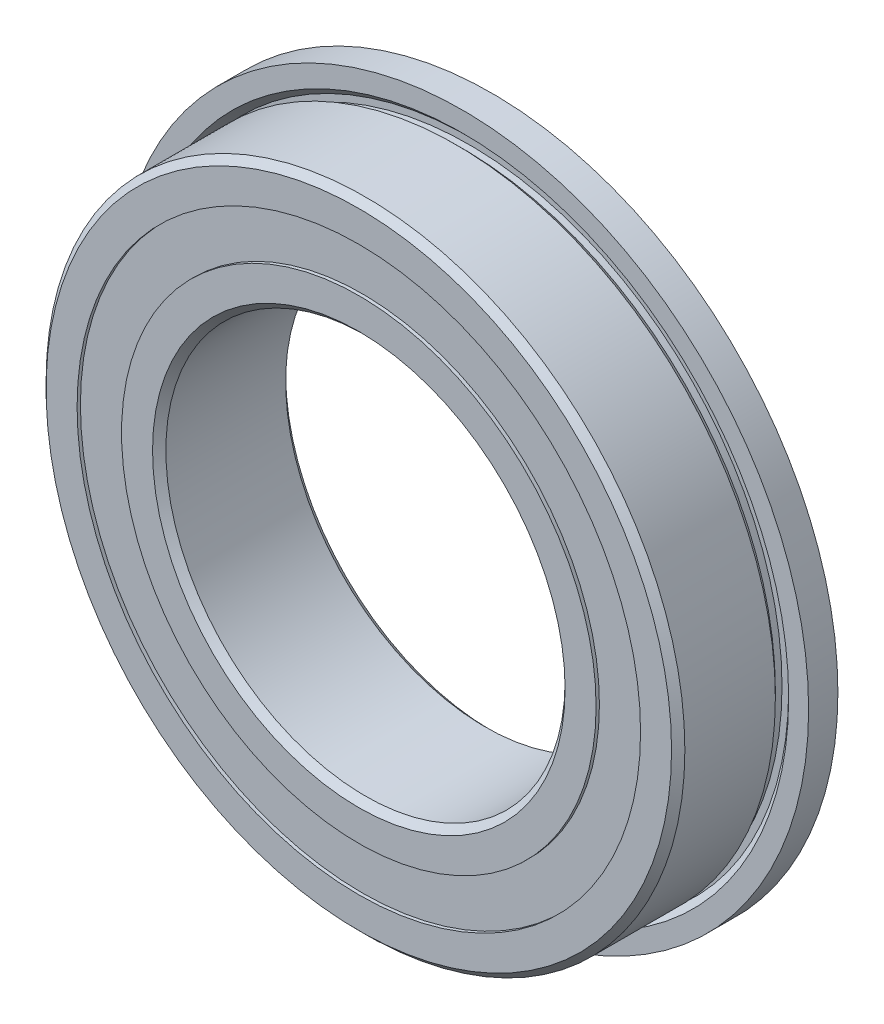
from build123d import *

# Parameters (mm, degrees)
SKETCH6_W         = 0.278388278
SKETCH6_H         = 0.835164836
CIRPATTERN1_COUNT = 14
SKETCH5_W         = 0.985011438
SKETCH5_H         = 1.67032967


with BuildPart() as part:
    # Sketch1 → Revolve1 (revolve)
    with BuildSketch(Plane(origin=(0, 0, 0), x_dir=(0, 0, -1), z_dir=(1, 0, 0))):
        with BuildLine():
            Line((-2.25, 12), (-2.5, 11.75))
            Line((-2.5, 11.75), (-2.5, 10.585164835))
            Line((-2.5, 10.585164835), (-1.111111111, 10.585164835))
            ThreePointArc((-1.111111111, 10.585164835), (0, 11.139988562), (1.111111111, 10.585164835))
            Line((1.111111111, 10.585164835), (2.5, 10.585164835))
            Line((2.5, 10.585164835), (2.5, 11.75))
            Line((2.5, 11.75), (2.5, 13))
            Line((2.5, 13), (1.4, 13))
            Line((1.4, 13), (1.4, 12.25))
            Line((1.4, 12.25), (1.65, 12))
            Line((1.65, 12), (1.65, 11.75))
            Line((1.65, 11.75), (1.4, 11.75))
            Line((1.4, 11.75), (1.15, 12))
            Line((1.15, 12), (-2.25, 12))
        make_face()
    revolve(axis=Axis((0, 0, 2.5), (0, 0, -1)))


with BuildPart() as body_2:
    # Sketch3 → Revolve3 (revolve)
    with BuildSketch(Plane(origin=(0, 0, 0), x_dir=(0, 0, -1), z_dir=(1, 0, 0))):
        with BuildLine():
            Line((-2.5, 8.914835165), (-1.111111111, 8.914835165))
            ThreePointArc((-1.111111111, 8.914835165), (0, 8.360011438), (1.111111111, 8.914835165))
            Line((1.111111111, 8.914835165), (2.5, 8.914835165))
            Line((2.5, 8.914835165), (2.5, 7.75))
            Line((2.5, 7.75), (2.25, 7.5))
            Line((2.25, 7.5), (-2.25, 7.5))
            Line((-2.25, 7.5), (-2.5, 7.75))
            Line((-2.5, 7.75), (-2.5, 8.914835165))
        make_face()
    revolve(axis=Axis((0, 0, 2.5), (0, 0, -1)))


with BuildPart() as body_3:
    # Sketch6 → Revolve6 (revolve)
    with BuildSketch(Plane(origin=(0, 0, 0), x_dir=(0, 0, -1), z_dir=(1, 0, 0))):
        with Locations((0, 9.75)):
            Rectangle(SKETCH6_W, SKETCH6_H)
    revolve(axis=Axis((0, 0, 2.5), (0, 0, -1)))


with BuildPart() as body_4:
    # Sketch4 → Revolve4 (revolve)
    with BuildSketch(Plane(origin=(0, 0, 0), x_dir=(0, 0, -1), z_dir=(1, 0, 0))):
        with BuildLine():
            Line((-1.389988562, 9.75), (1.389988562, 9.75))
            ThreePointArc((1.389988562, 9.75), (0, 11.139988562), (-1.389988562, 9.75))
        make_face()
    revolve(axis=Axis((0, 9.75, 1.389988562), (0, 0, -1)))


with BuildPart() as cirpattern1_1:
    # CirPattern1: pattern copy
    add(body_4.part.rotate(Axis((0, 0, -2.5), (0, 0, 1)), 1 * 360 / CIRPATTERN1_COUNT))


with BuildPart() as cirpattern1_2:
    # CirPattern1: pattern copy
    add(body_4.part.rotate(Axis((0, 0, -2.5), (0, 0, 1)), 2 * 360 / CIRPATTERN1_COUNT))


with BuildPart() as cirpattern1_3:
    # CirPattern1: pattern copy
    add(body_4.part.rotate(Axis((0, 0, -2.5), (0, 0, 1)), 3 * 360 / CIRPATTERN1_COUNT))


with BuildPart() as cirpattern1_4:
    # CirPattern1: pattern copy
    add(body_4.part.rotate(Axis((0, 0, -2.5), (0, 0, 1)), 4 * 360 / CIRPATTERN1_COUNT))


with BuildPart() as cirpattern1_5:
    # CirPattern1: pattern copy
    add(body_4.part.rotate(Axis((0, 0, -2.5), (0, 0, 1)), 5 * 360 / CIRPATTERN1_COUNT))


with BuildPart() as cirpattern1_6:
    # CirPattern1: pattern copy
    add(body_4.part.rotate(Axis((0, 0, -2.5), (0, 0, 1)), 6 * 360 / CIRPATTERN1_COUNT))


with BuildPart() as cirpattern1_7:
    # CirPattern1: pattern copy
    add(body_4.part.rotate(Axis((0, 0, -2.5), (0, 0, 1)), 7 * 360 / CIRPATTERN1_COUNT))


with BuildPart() as cirpattern1_8:
    # CirPattern1: pattern copy
    add(body_4.part.rotate(Axis((0, 0, -2.5), (0, 0, 1)), 8 * 360 / CIRPATTERN1_COUNT))


with BuildPart() as cirpattern1_9:
    # CirPattern1: pattern copy
    add(body_4.part.rotate(Axis((0, 0, -2.5), (0, 0, 1)), 9 * 360 / CIRPATTERN1_COUNT))


with BuildPart() as cirpattern1_10:
    # CirPattern1: pattern copy
    add(body_4.part.rotate(Axis((0, 0, -2.5), (0, 0, 1)), 10 * 360 / CIRPATTERN1_COUNT))


with BuildPart() as cirpattern1_11:
    # CirPattern1: pattern copy
    add(body_4.part.rotate(Axis((0, 0, -2.5), (0, 0, 1)), 11 * 360 / CIRPATTERN1_COUNT))


with BuildPart() as cirpattern1_12:
    # CirPattern1: pattern copy
    add(body_4.part.rotate(Axis((0, 0, -2.5), (0, 0, 1)), 12 * 360 / CIRPATTERN1_COUNT))


with BuildPart() as cirpattern1_13:
    # CirPattern1: pattern copy
    add(body_4.part.rotate(Axis((0, 0, -2.5), (0, 0, 1)), 13 * 360 / CIRPATTERN1_COUNT))


with BuildPart() as body_18:
    # Sketch5 → Revolve5 (revolve)
    with BuildSketch(Plane(origin=(0, 0, 0), x_dir=(0, 0, -1), z_dir=(1, 0, 0))):
        with Locations((-1.882494281, 9.75)):
            Rectangle(SKETCH5_W, SKETCH5_H)
        with Locations((1.882494281, 9.75)):
            Rectangle(SKETCH5_W, SKETCH5_H)
    revolve(axis=Axis((0, 0, 2.5), (0, 0, -1)))


solid = Compound([part.part, body_2.part, body_3.part, body_4.part, cirpattern1_1.part, cirpattern1_2.part, cirpattern1_3.part, cirpattern1_4.part, cirpattern1_5.part, cirpattern1_6.part, cirpattern1_7.part, cirpattern1_8.part, cirpattern1_9.part, cirpattern1_10.part, cirpattern1_11.part, cirpattern1_12.part, cirpattern1_13.part, body_18.part])
